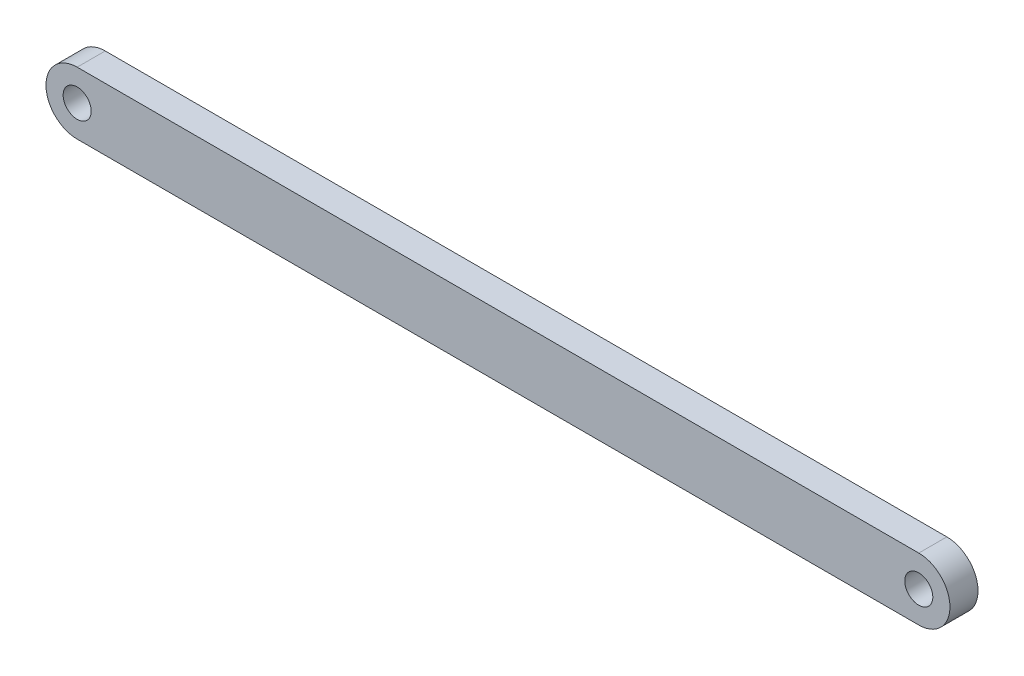
from build123d import *

# Parameters (mm, degrees)
SZKIC1_R                    = 9
DODANIE_WYCI_GNI_CIE2_DEPTH = 18


with BuildPart() as part:
    # Szkic1 → Dodanie-wyciągnięcie2 (new body)
    with BuildSketch(Plane.XY):
        with BuildLine():
            Line((0, 20), (540, 20))
            ThreePointArc((540, 20), (560, -2.244e-06), (539.999995511, -20))
            Line((539.999995511, -20), (0, -20))
            ThreePointArc((0, -20), (-20, 0), (0, 20))
        make_face()
        Circle(SZKIC1_R, mode=Mode.SUBTRACT)
        with Locations((540, 0)):
            Circle(SZKIC1_R, mode=Mode.SUBTRACT)
    extrude(amount=DODANIE_WYCI_GNI_CIE2_DEPTH)


solid = part.part
